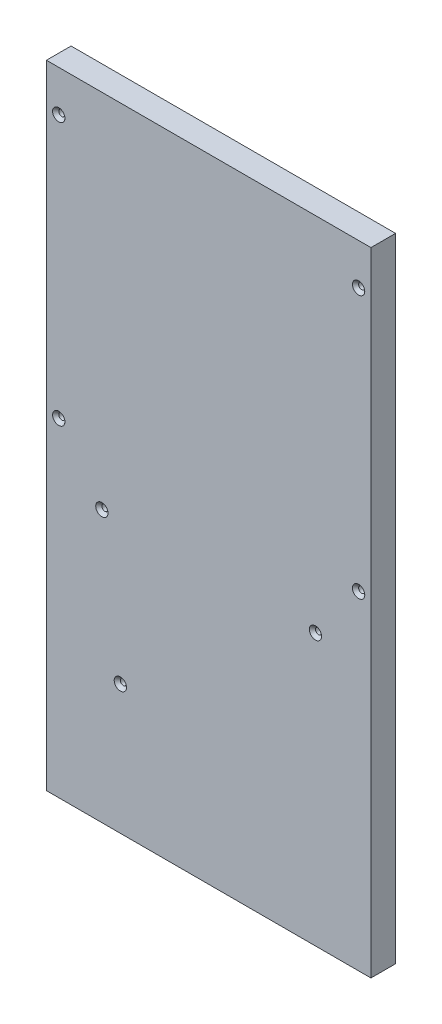
from build123d import *

# Parameters (mm, degrees)
SKETCH1_W           = 158
SKETCH1_H           = 308
SKETCH1_R           = 1.5
BOSS_EXTRUDE1_DEPTH = 12
CUT_EXTRUDE3_START  = -196.463415
SKETCH4_R           = 1.5
CUT_EXTRUDE3_DEPTH  = 20
SKETCH6_R           = 7
CUT_EXTRUDE5_DEPTH  = 5


with BuildPart() as part:
    # Sketch1 → Boss-Extrude1 (new body)
    with BuildSketch(Plane.XY):
        with Locations((-85.951219512, -42.463414634)):
            Rectangle(SKETCH1_W, SKETCH1_H)
        with Locations((-137.951219512, -64.463414634)):
            Circle(SKETCH1_R, mode=Mode.SUBTRACT)
        with Locations((-33.951219512, -64.463414634)):
            Circle(SKETCH1_R, mode=Mode.SUBTRACT)
        with Locations((-128.951219512, -133.463414634)):
            Circle(SKETCH1_R, mode=Mode.SUBTRACT)
        with Locations((-158.951219512, 91.536585366)):
            Circle(SKETCH1_R, mode=Mode.SUBTRACT)
        with Locations((-158.951219512, -36.463414634)):
            Circle(SKETCH1_R, mode=Mode.SUBTRACT)
        with Locations((-12.951219512, 91.536585366)):
            Circle(SKETCH1_R, mode=Mode.SUBTRACT)
        with Locations((-12.951219512, -36.463414634)):
            Circle(SKETCH1_R, mode=Mode.SUBTRACT)
    extrude(amount=BOSS_EXTRUDE1_DEPTH)

    # Sketch4 → Cut-Extrude3 (cut)
    with BuildSketch(Plane(origin=(0, 0, 0), x_dir=(1, 0, 0), z_dir=(0, 1, 0)).offset(CUT_EXTRUDE3_START)):
        with Locations(Location((-149.951219512, -6, 0), (0, 0, 270))):
            Circle(SKETCH4_R)
        with Locations(Location((-21.951219512, -6, 0), (0, 0, 270))):
            Circle(SKETCH4_R)
    extrude(amount=CUT_EXTRUDE3_DEPTH, mode=Mode.SUBTRACT)

    # Cut-Extrude4 cone 1 section (through the dimple's axis) → Cut-Extrude4 (revolve, cut)
    with BuildSketch(Plane(origin=(-137.951219512, -64.463414634, 12), x_dir=(0, -1, 0), z_dir=(1, 0, 0))):
        Polygon((0, 0), (3, 0), (0, 3), align=None)
    revolve(axis=Axis((-137.951219512, -64.463414634, 12), (0, 0, -1)), mode=Mode.SUBTRACT)

    # Cut-Extrude4 cone 2 section (through the dimple's axis) → Cut-Extrude4 cone 2 (revolve, cut)
    with BuildSketch(Plane(origin=(-33.951219512, -64.463414634, 12), x_dir=(0, -1, 0), z_dir=(1, 0, 0))):
        Polygon((0, 0), (3, 0), (0, 3), align=None)
    revolve(axis=Axis((-33.951219512, -64.463414634, 12), (0, 0, -1)), mode=Mode.SUBTRACT)

    # Cut-Extrude4 cone 3 section (through the dimple's axis) → Cut-Extrude4 cone 3 (revolve, cut)
    with BuildSketch(Plane(origin=(-128.951219512, -133.463414634, 12), x_dir=(0, -1, 0), z_dir=(1, 0, 0))):
        Polygon((0, 0), (3, 0), (0, 3), align=None)
    revolve(axis=Axis((-128.951219512, -133.463414634, 12), (0, 0, -1)), mode=Mode.SUBTRACT)

    # Cut-Extrude4 cone 4 section (through the dimple's axis) → Cut-Extrude4 cone 4 (revolve, cut)
    with BuildSketch(Plane(origin=(-158.951219512, 91.536585366, 12), x_dir=(0, -1, 0), z_dir=(1, 0, 0))):
        Polygon((0, 0), (3, 0), (0, 3), align=None)
    revolve(axis=Axis((-158.951219512, 91.536585366, 12), (0, 0, -1)), mode=Mode.SUBTRACT)

    # Cut-Extrude4 cone 5 section (through the dimple's axis) → Cut-Extrude4 cone 5 (revolve, cut)
    with BuildSketch(Plane(origin=(-158.951219512, -36.463414634, 12), x_dir=(0, -1, 0), z_dir=(1, 0, 0))):
        Polygon((0, 0), (3, 0), (0, 3), align=None)
    revolve(axis=Axis((-158.951219512, -36.463414634, 12), (0, 0, -1)), mode=Mode.SUBTRACT)

    # Cut-Extrude4 cone 6 section (through the dimple's axis) → Cut-Extrude4 cone 6 (revolve, cut)
    with BuildSketch(Plane(origin=(-12.951219512, 91.536585366, 12), x_dir=(0, -1, 0), z_dir=(1, 0, 0))):
        Polygon((0, 0), (3, 0), (0, 3), align=None)
    revolve(axis=Axis((-12.951219512, 91.536585366, 12), (0, 0, -1)), mode=Mode.SUBTRACT)

    # Cut-Extrude4 cone 7 section (through the dimple's axis) → Cut-Extrude4 cone 7 (revolve, cut)
    with BuildSketch(Plane(origin=(-12.951219512, -36.463414634, 12), x_dir=(0, -1, 0), z_dir=(1, 0, 0))):
        Polygon((0, 0), (3, 0), (0, 3), align=None)
    revolve(axis=Axis((-12.951219512, -36.463414634, 12), (0, 0, -1)), mode=Mode.SUBTRACT)

    # Sketch6 → Cut-Extrude5 (cut)
    with BuildSketch(Plane.XY):
        with Locations((-45.951219512, -31.463414634)):
            Circle(SKETCH6_R)
    extrude(amount=CUT_EXTRUDE5_DEPTH, mode=Mode.SUBTRACT)


solid = part.part
